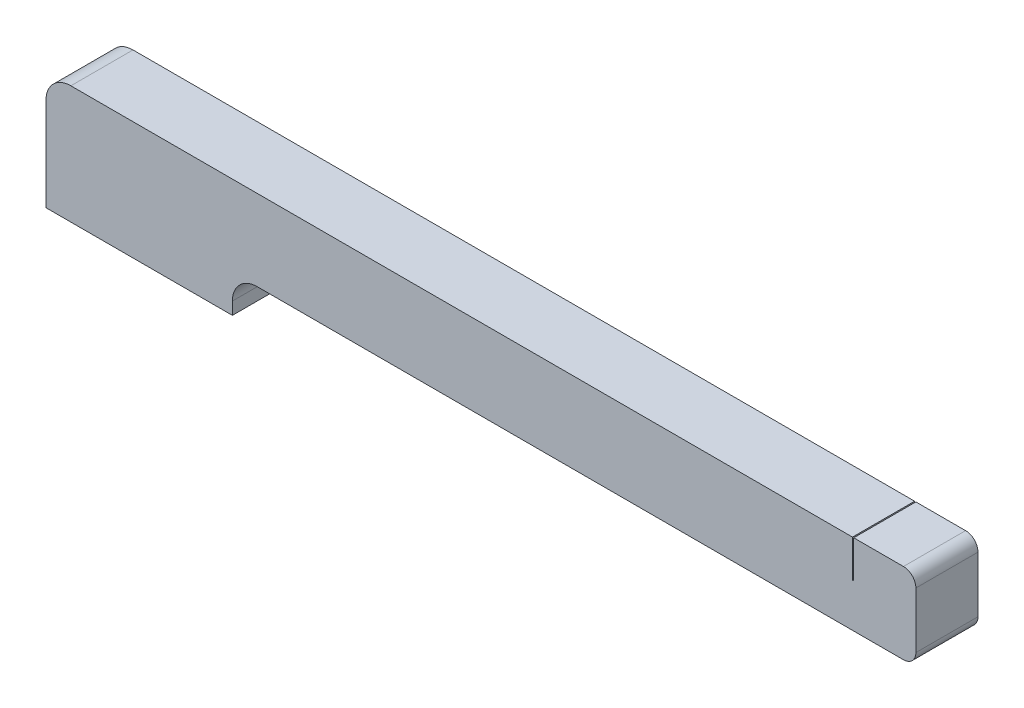
from build123d import *

# Parameters (mm, degrees)
BOSS_EXTRUDE1_DEPTH = 5
SKETCH3_W           = 0.1
SKETCH3_H           = 5
CUT_EXTRUDE1_DEPTH  = 3


with BuildPart() as part:
    # Sketch1 → Boss-Extrude1 (new body)
    with BuildSketch(Plane.XY):
        with BuildLine():
            Line((0, 0), (0, 7.5))
            ThreePointArc((0, 7.5), (0.585786438, 8.914213562), (2, 9.5))
            Line((2, 9.5), (69, 9.5))
            ThreePointArc((69, 9.5), (69.707106781, 9.207106781), (70, 8.5))
            Line((70, 8.5), (70, 4))
            ThreePointArc((70, 4), (69.707106781, 3.292893219), (69, 3))
            Line((69, 3), (17, 3))
            ThreePointArc((17, 3), (15.585786438, 2.414213562), (15, 1))
            Line((15, 1), (15, 0))
            Line((15, 0), (11, 0))
            Line((11, 0), (4, 0))
            Line((4, 0), (0, 0))
        make_face()
    extrude(amount=BOSS_EXTRUDE1_DEPTH)

    # Sketch3 → Cut-Extrude1 (cut)
    with BuildSketch(Plane(origin=(0, 9.5, 0), x_dir=(1, 0, 0), z_dir=(0, 1, 0))):
        with Locations((64.95, -2.5)):
            Rectangle(SKETCH3_W, SKETCH3_H)
    extrude(amount=-CUT_EXTRUDE1_DEPTH, mode=Mode.SUBTRACT)


solid = part.part
